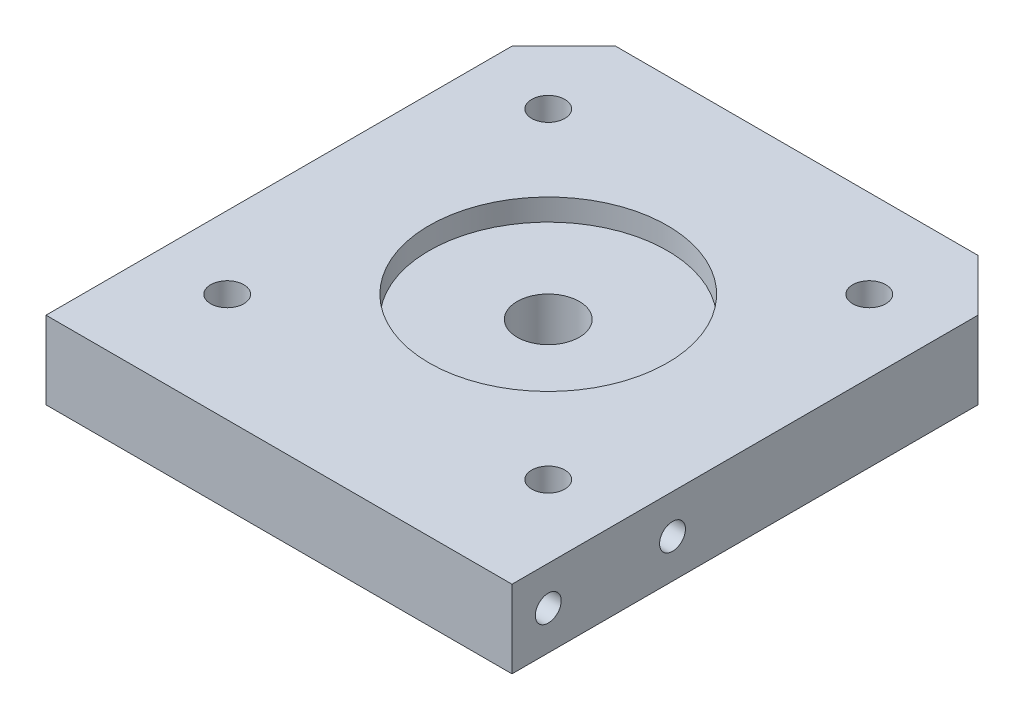
from build123d import *

# Parameters (mm, degrees)
SKETCH3_W                                           = 45
SKETCH3_H                                           = 45
SKETCH3_R                                           = 3
BOSS_EXTRUDE2_DEPTH                                 = 7.5
SKETCH5_R                                           = 11.5
CUT_EXTRUDE1_DEPTH                                  = 2.1
CHAMFER1_SIZE                                       = 5
CBORE_FOR_M3_HEX_SOCKET_HEAD_CAP_SCREW1_D           = 3.2
CBORE_FOR_M3_HEX_SOCKET_HEAD_CAP_SCREW1_DEPTH       = 7.5
CBORE_FOR_M3_HEX_SOCKET_HEAD_CAP_SCREW1_CBORE_D     = 6.5
CBORE_FOR_M3_HEX_SOCKET_HEAD_CAP_SCREW1_CBORE_DEPTH = 3.5
SKETCH10_W                                          = 45
SKETCH10_H                                          = 7.5
BOSS_EXTRUDE3_DEPTH                                 = 5
M3_TAPPED_HOLE2_AT_2_COUNT                          = 2
M3_TAPPED_HOLE2_AT_2_PITCH                          = 12


with BuildPart() as part:
    # Sketch3 → Boss-Extrude2 (new body)
    with BuildSketch(Plane(origin=(0, 0, 0), x_dir=(1, 0, 0), z_dir=(0, 1, 0))):
        Rectangle(SKETCH3_W, SKETCH3_H)
        with Locations((0, -1.5)):
            Circle(SKETCH3_R, mode=Mode.SUBTRACT)
    extrude(amount=BOSS_EXTRUDE2_DEPTH)

    # Sketch5 → Cut-Extrude1 (cut)
    with BuildSketch(Plane(origin=(0, 7.5, 0), x_dir=(1, 0, 0), z_dir=(0, 1, 0))):
        with Locations((0, -1.5)):
            Circle(SKETCH5_R)
    extrude(amount=-CUT_EXTRUDE1_DEPTH, mode=Mode.SUBTRACT)

    # Chamfer1
    chamfer1_edges = [part.edges().sort_by_distance(p)[0] for p in [
        (-22.5, 3.75, -22.5),
        (22.5, 3.75, -22.5),
    ]]
    chamfer(chamfer1_edges, length=CHAMFER1_SIZE)

    # CBORE for M3 Hex Socket Head Cap Screw1
    with Locations(Plane(origin=(0, 0, 0), x_dir=(-1, 0, 0), z_dir=(0, -1, 0))):
        with Locations((15.5, 14), (-15.5, -17), (-15.5, 14), (15.5, -17)):
            CounterBoreHole(CBORE_FOR_M3_HEX_SOCKET_HEAD_CAP_SCREW1_D / 2, CBORE_FOR_M3_HEX_SOCKET_HEAD_CAP_SCREW1_CBORE_D / 2, CBORE_FOR_M3_HEX_SOCKET_HEAD_CAP_SCREW1_CBORE_DEPTH, depth=CBORE_FOR_M3_HEX_SOCKET_HEAD_CAP_SCREW1_DEPTH)

    # Sketch10 → Boss-Extrude3 (add)
    with BuildSketch(Plane.XY.offset(22.5)):
        with Locations((0, 3.75)):
            Rectangle(SKETCH10_W, SKETCH10_H)
    extrude(amount=BOSS_EXTRUDE3_DEPTH)

    # Sketch14 → M3 Tapped Hole2 (revolve, cut)
    with BuildSketch(Plane(origin=(-22.5, 3.75, 24), x_dir=(0, 0, 1), z_dir=(0, 1, 0))):
        Polygon((0, 0), (0, 10.751075774), (1.25, 10), (1.25, 0), align=None)
    m3_tapped_hole2 = revolve(axis=Axis((-28.85, 3.75, 24), (1, 0, 0)), mode=Mode.SUBTRACT)

    # M3 Tapped Hole2 at 2: M3 Tapped Hole2 ×2
    with Locations(*[(0, 0, -i * M3_TAPPED_HOLE2_AT_2_PITCH) for i in range(1, M3_TAPPED_HOLE2_AT_2_COUNT)]):
        add(m3_tapped_hole2, mode=Mode.SUBTRACT)

    # Mirror1: M3 Tapped Hole2 across plane
    add(m3_tapped_hole2.mirror(Plane(origin=(0, 0, 0), x_dir=(0, 0, 1), z_dir=(1, 0, 0))), mode=Mode.SUBTRACT)

    # Mirror1 copy 1 sketch → Mirror1 copy 1 (revolve, cut)
    with BuildSketch(Plane(origin=(22.5, 3.75, 12), x_dir=(0, 0, 1), z_dir=(0, 1, 0))):
        Polygon((0, 0), (0, -10.751075774), (1.25, -10), (1.25, 0), align=None)
    revolve(axis=Axis((28.85, 3.75, 12), (1, 0, 0)), mode=Mode.SUBTRACT)


solid = part.part
